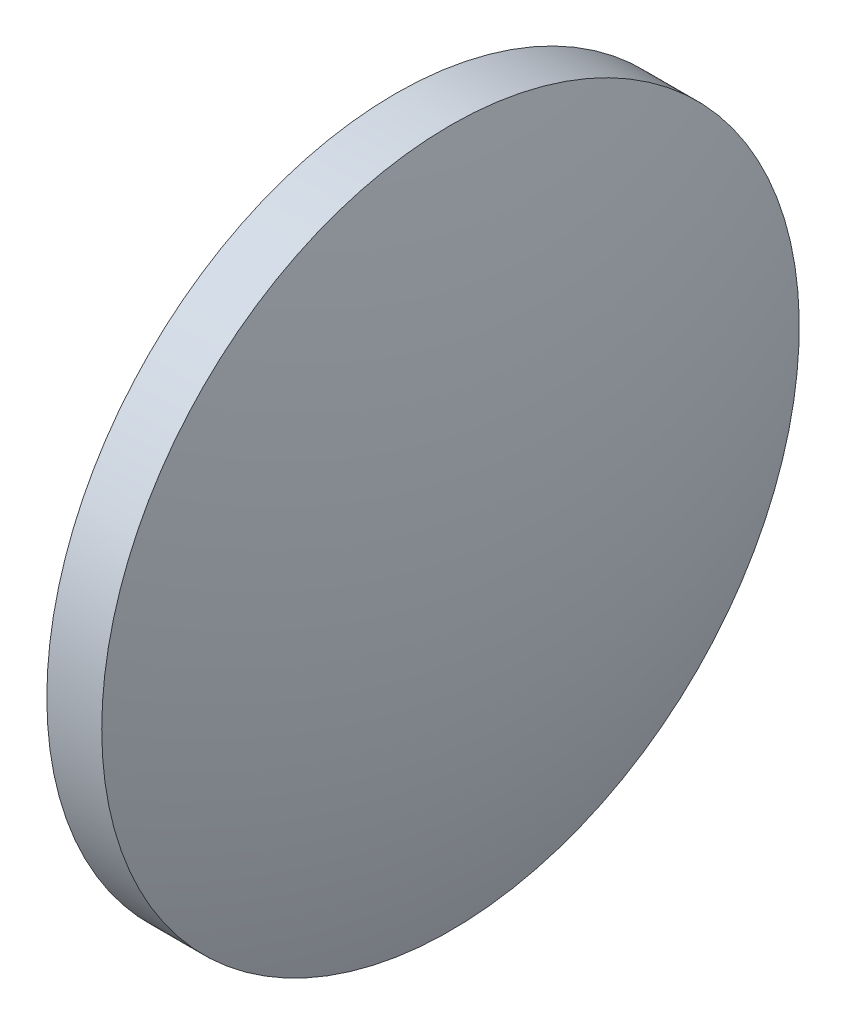
from build123d import *

# Parameters (mm, degrees)
SKETCH_1_ONE_SIDE_W = 1.999342857
SKETCH_1_ONE_SIDE_H = 12.7


with BuildPart() as part:
    # 草图1 one side → 旋转1 (revolve)
    with BuildSketch(Plane.XY):
        with Locations((86.458193775, 54.966113023)):
            Rectangle(SKETCH_1_ONE_SIDE_W, SKETCH_1_ONE_SIDE_H)
        with BuildLine():
            Line((83.508201489, 48.616113023), (85.458522346, 48.616113023))
            Line((85.458522346, 48.616113023), (85.458522346, 61.316113023))
            ThreePointArc((85.458522346, 61.316113023), (83.998622986, 55.040553688), (83.508201489, 48.616113023))
        make_face()
        with BuildLine():
            Line((87.457865203, 48.616113023), (89.40818606, 48.616113023))
            ThreePointArc((89.40818606, 48.616113023), (88.917764564, 55.040553688), (87.457865203, 61.316113023))
            Line((87.457865203, 61.316113023), (87.457865203, 48.616113023))
        make_face()
    revolve(axis=Axis((79.305401351, 48.616113023, 0), (1, 0, 0)))


solid = part.part
